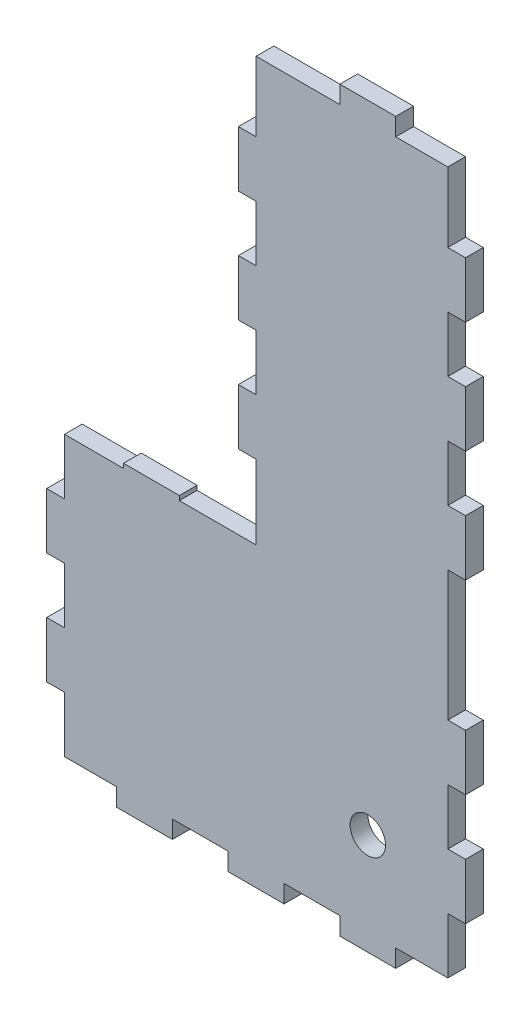
from build123d import *

# Parameters (mm, degrees)
SKETCH1_R           = 19.125454448
SKETCH1_W           = 20
SKETCH1_H           = 1.5875
SKETCH1_W_2         = 6.35
SKETCH1_H_2         = 20
SKETCH1_H_3         = 6.35
SKETCH1_R_2         = 6.35
BOSS_EXTRUDE1_DEPTH = 6.35


with BuildPart() as part:
    # Sketch1 → Boss-Extrude1 (new body)
    with BuildSketch(Plane.XY):
        Polygon((71.384937154, 207.60103085), (71.384937154, 227.60103085), (71.384937154, 252.60103085), (52.734937154, 252.60103085), (32.734937154, 252.60103085), (2.734937154, 252.60103085), (2.734937154, 227.60103085), (2.734937154, 207.60103085), (2.734937154, 187.60103085), (2.734937154, 167.60103085), (2.734937154, 147.60103085), (2.734937154, 127.60103085), (2.734937154, 102.60103085), (2.734937154, 101.01353085), (-24.765062846, 101.01353085), (-44.765062846, 101.01353085), (-65.915062846, 101.01353085), (-65.915062846, 81.01353085), (-65.915062846, 61.01353085), (-65.915062846, 41.01353085), (-65.915062846, 21.01353085), (-65.915062846, 1.01353085), (-47.265062846, 1.01353085), (-27.265062846, 1.01353085), (-7.265062846, 1.01353085), (12.734937154, 1.01353085), (32.734937154, 1.01353085), (52.734937154, 1.01353085), (71.384937154, 1.01353085), (71.384937154, 21.01353085), (71.384937154, 41.01353085), (71.384937154, 61.01353085), (71.384937154, 81.01353085), (71.384937154, 127.60103085), (71.384937154, 147.60103085), (71.384937154, 167.60103085), (71.384937154, 187.60103085), align=None)
        with Locations((42.734937154, 31.01353085)):
            Circle(SKETCH1_R, mode=Mode.SUBTRACT)
        with Locations((-34.765062846, 101.80728085)):
            Rectangle(SKETCH1_W, SKETCH1_H)
        with Locations((-69.090062846, 71.01353085)):
            Rectangle(SKETCH1_W_2, SKETCH1_H_2)
        with Locations((-69.090062846, 31.01353085)):
            Rectangle(SKETCH1_W_2, SKETCH1_H_2)
        with Locations((-37.265062846, -2.16146915)):
            Rectangle(SKETCH1_W, SKETCH1_H_3)
        with Locations((2.734937154, -2.16146915)):
            Rectangle(SKETCH1_W, SKETCH1_H_3)
        with Locations((42.734937154, -2.16146915)):
            Rectangle(SKETCH1_W, SKETCH1_H_3)
        with Locations((74.559937154, 31.01353085)):
            Rectangle(SKETCH1_W_2, SKETCH1_H_2)
        with Locations((74.559937154, 71.01353085)):
            Rectangle(SKETCH1_W_2, SKETCH1_H_2)
        with Locations((74.559937154, 137.60103085)):
            Rectangle(SKETCH1_W_2, SKETCH1_H_2)
        with Locations((74.559937154, 177.60103085)):
            Rectangle(SKETCH1_W_2, SKETCH1_H_2)
        with Locations((74.559937154, 217.60103085)):
            Rectangle(SKETCH1_W_2, SKETCH1_H_2)
        with Locations((42.734937154, 255.77603085)):
            Rectangle(SKETCH1_W, SKETCH1_H_3)
        with Locations((-0.440062846, 217.60103085)):
            Rectangle(SKETCH1_W_2, SKETCH1_H_2)
        with Locations((-0.440062846, 177.60103085)):
            Rectangle(SKETCH1_W_2, SKETCH1_H_2)
        with Locations((-0.440062846, 137.60103085)):
            Rectangle(SKETCH1_W_2, SKETCH1_H_2)
        with Locations((42.734937154, 31.01353085)):
            Circle(SKETCH1_R)
        with Locations((42.734937154, 31.01353085)):
            Circle(SKETCH1_R_2, mode=Mode.SUBTRACT)
    extrude(amount=-BOSS_EXTRUDE1_DEPTH)


solid = part.part
